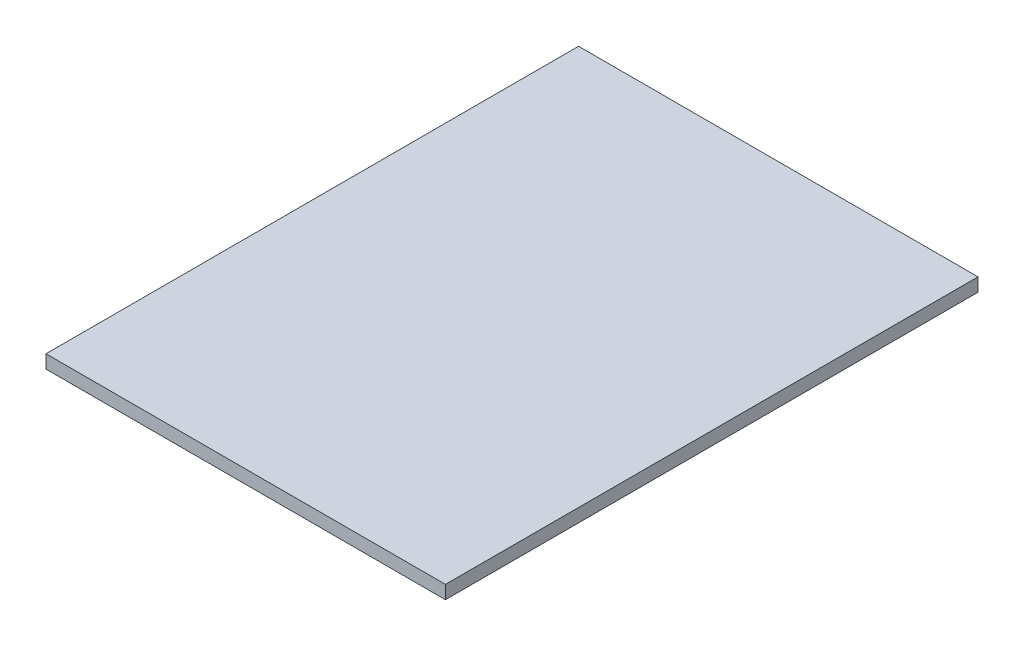
from build123d import *

# Parameters (mm, degrees)
ESQUISSE1_W      = 300
ESQUISSE1_H      = 400
EXTRUSION1_DEPTH = 10


with BuildPart() as part:
    # Esquisse1 → Extrusion1 (new body)
    with BuildSketch(Plane(origin=(0, 0, 0), x_dir=(1, 0, 0), z_dir=(0, 1, 0))):
        with Locations((150, 200)):
            Rectangle(ESQUISSE1_W, ESQUISSE1_H)
    extrude(amount=EXTRUSION1_DEPTH)


solid = part.part
